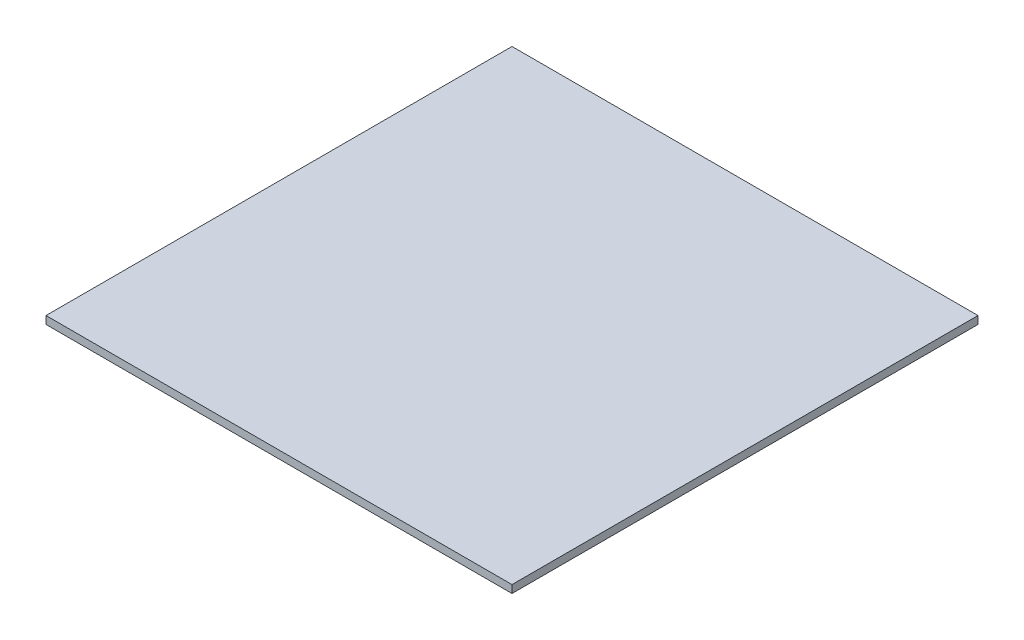
from build123d import *

# Parameters (mm, degrees)
ESQUISSE1_W      = 300
ESQUISSE1_H      = 300
EXTRUSION1_DEPTH = 5


with BuildPart() as part:
    # Esquisse1 → Extrusion1 (new body)
    with BuildSketch(Plane(origin=(0, 0, 0), x_dir=(1, 0, 0), z_dir=(0, 1, 0))):
        with Locations((150, 150)):
            Rectangle(ESQUISSE1_W, ESQUISSE1_H)
    extrude(amount=EXTRUSION1_DEPTH)


solid = part.part
